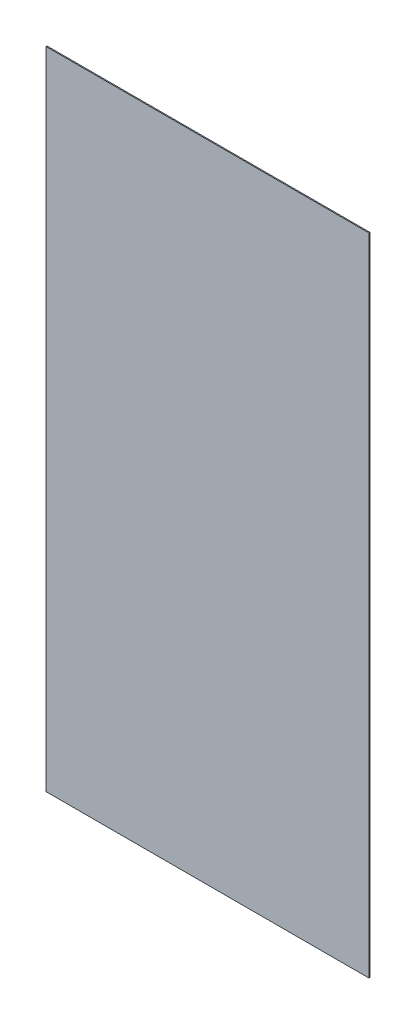
from build123d import *

# Parameters (mm, degrees)
SKETCH1_W           = 242.4
SKETCH1_H           = 484.8
BOSS_EXTRUDE1_DEPTH = 0.75


with BuildPart() as part:
    # Sketch1 → Boss-Extrude1 (new body)
    with BuildSketch(Plane.XY):
        with Locations((121.2, 242.4)):
            Rectangle(SKETCH1_W, SKETCH1_H)
    extrude(amount=BOSS_EXTRUDE1_DEPTH)


solid = part.part
